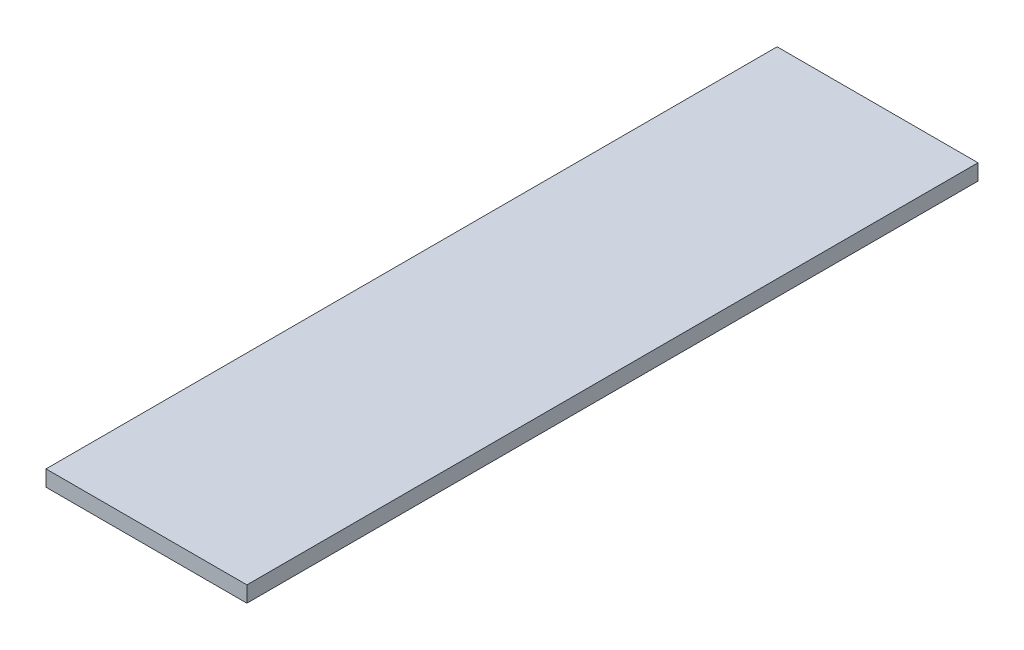
from build123d import *

# Parameters (mm, degrees)
SKETCH1_W           = 40.132
SKETCH1_H           = 3.175
BOSS_EXTRUDE1_DEPTH = 146.05


with BuildPart() as part:
    # Sketch1 → Boss-Extrude1 (new body)
    with BuildSketch(Plane.XY):
        with Locations((20.066, 1.5875)):
            Rectangle(SKETCH1_W, SKETCH1_H)
    extrude(amount=BOSS_EXTRUDE1_DEPTH)


solid = part.part
